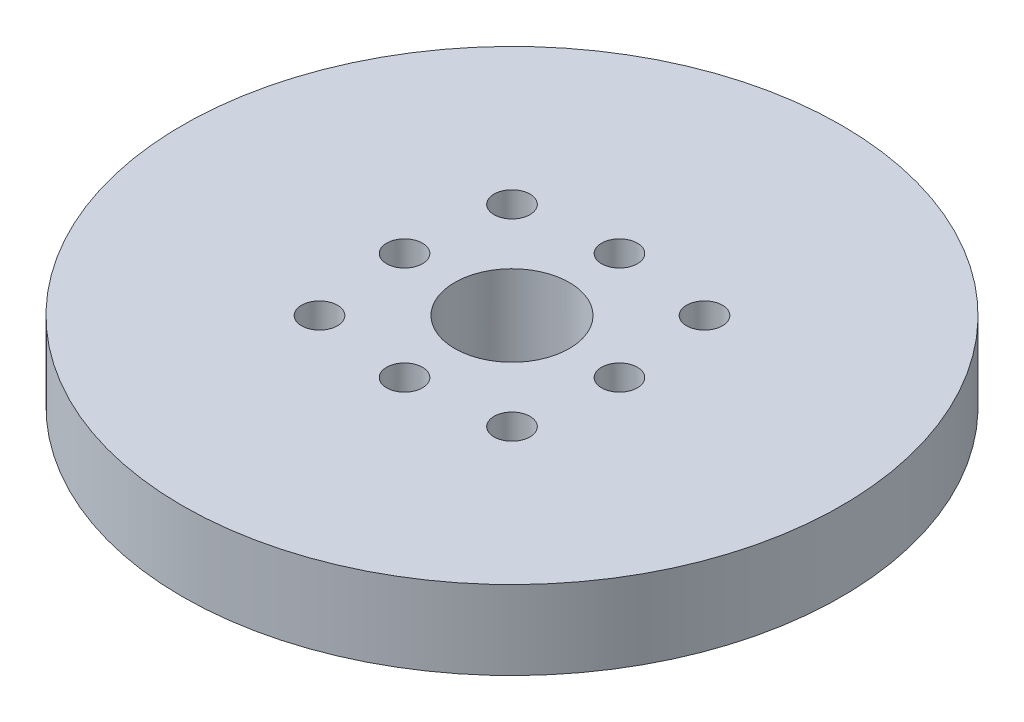
from build123d import *

# Parameters (mm, degrees)
SKETCH1_R                 = 23
BOSS_EXTRUDE1_DEPTH       = 5.5
SKETCH2_R                 = 4
CUT_EXTRUDE1_DEPTH        = 5.5
M3X0_5_TAPPED_HOLE1_D     = 2.5
M3X0_5_TAPPED_HOLE1_DEPTH = 6.5
M3X0_5_TAPPED_HOLE1_TIP   = 0.751075774
SKETCH6_R                 = 6
SKETCH6_R_2               = 4
BOSS_EXTRUDE2_DEPTH       = 1


with BuildPart() as part:
    # Sketch1 → Boss-Extrude1 (new body)
    with BuildSketch(Plane(origin=(0, 0, 0), x_dir=(1, 0, 0), z_dir=(0, 1, 0))):
        Circle(SKETCH1_R)
    extrude(amount=BOSS_EXTRUDE1_DEPTH)

    # Sketch2 → Cut-Extrude1 (cut)
    with BuildSketch(Plane(origin=(0, 5.5, 0), x_dir=(1, 0, 0), z_dir=(0, 1, 0))):
        Circle(SKETCH2_R)
    extrude(amount=-CUT_EXTRUDE1_DEPTH, mode=Mode.SUBTRACT)

    # M3x0.5 Tapped Hole1
    with Locations(Plane(origin=(0, 0, 0), x_dir=(-1, 0, 0), z_dir=(0, -1, 0))):
        with Locations((6.717514421, -6.717514421), (-7.5, 0), (0, 7.5), (7.5, 0), (0, -7.5), (-6.717514421, -6.717514421), (-6.717514421, 6.717514421), (6.717514421, 6.717514421)):
            Hole(M3X0_5_TAPPED_HOLE1_D / 2, depth=M3X0_5_TAPPED_HOLE1_DEPTH)
            with Locations((0, 0, -(M3X0_5_TAPPED_HOLE1_DEPTH + M3X0_5_TAPPED_HOLE1_TIP / 2))):  # 118° drill point
                Cone(0, M3X0_5_TAPPED_HOLE1_D / 2, M3X0_5_TAPPED_HOLE1_TIP, mode=Mode.SUBTRACT)

    # Sketch6 → Boss-Extrude2 (add)
    with BuildSketch(Plane.XZ):
        Circle(SKETCH6_R)
        Circle(SKETCH6_R_2, mode=Mode.SUBTRACT)
    extrude(amount=BOSS_EXTRUDE2_DEPTH)


solid = part.part
